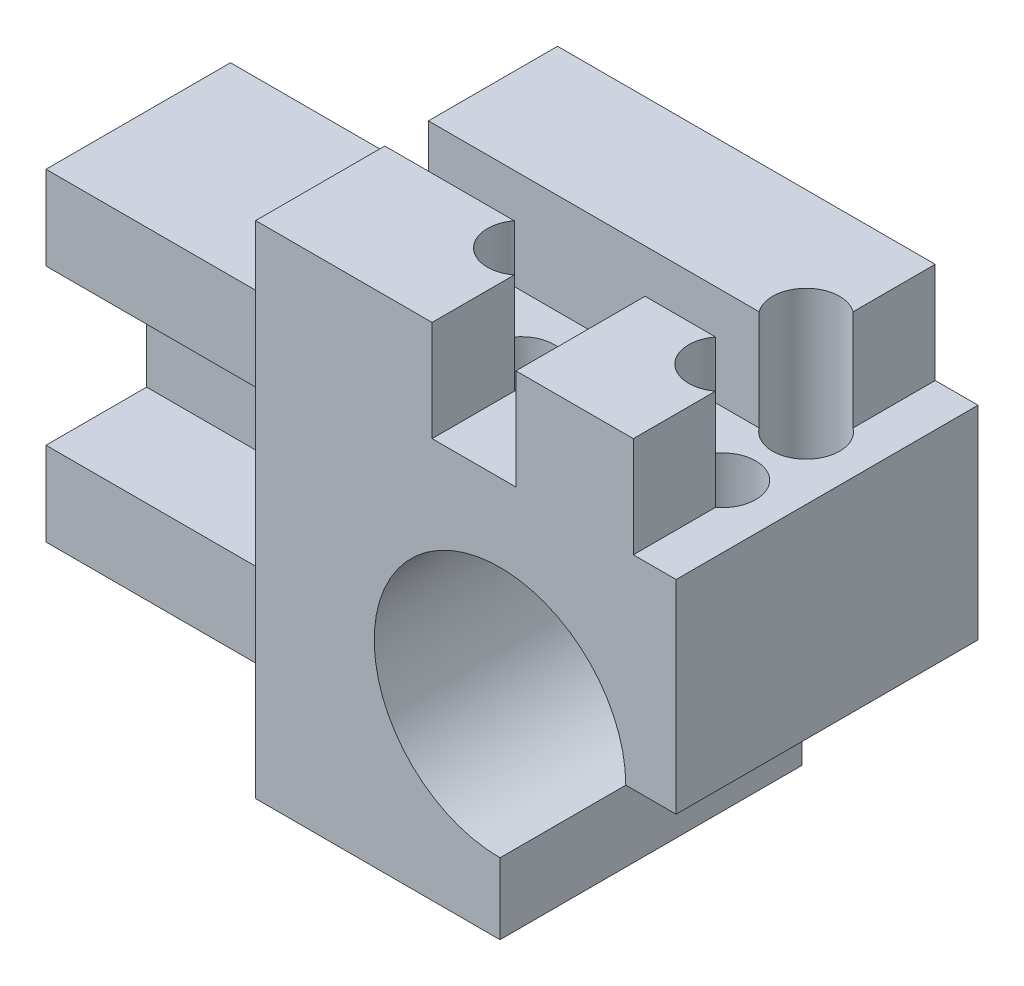
from build123d import *

# Parameters (mm, degrees)
SKETCH1_W               = 8.56892
SKETCH1_H               = 8.11892
BOSS_EXTRUDE1_DEPTH     = 9
SKETCH4_W               = 19.5
SKETCH4_H               = 19.25
BOSS_EXTRUDE2_DEPTH     = 5
SKETCH5_W               = 19.5
SKETCH5_H               = 5
BOSS_EXTRUDE3_DEPTH     = 6
CUT_EXTRUDE1_DEPTH      = 6
SKETCH7_R               = 2
CUT_EXTRUDE2_DEPTH      = 10
CUT_EXTRUDE3_DEPTH      = 6
SKETCH11_R              = 7.5
SKETCH11_W              = 10.5
SKETCH11_H              = 11.73108
CUT_EXTRUDE5_DEPTH      = 10
CUT_EXTRUDE5_DEPTH_BACK = 10


with BuildPart() as part:
    # Sketch1 → Boss-Extrude1 (new body, symmetric)
    with BuildSketch(Plane.XY):
        Polygon((-16.5, -19.85), (0, -19.85), (0, 0), (8.56892, 0), (8.56892, 10), (-16.5, 10), align=None)
        with Locations((4.28446, -4.05946)):
            Rectangle(SKETCH1_W, SKETCH1_H)
    extrude(amount=BOSS_EXTRUDE1_DEPTH, both=True)

    # Sketch4 → Boss-Extrude2 (add)
    with BuildSketch(Plane(origin=(0, 0, -9), x_dir=(-1, 0, 0), z_dir=(0, 0, -1))):
        with Locations((26.25, -10.225)):
            Rectangle(SKETCH4_W, SKETCH4_H)
    extrude(amount=-BOSS_EXTRUDE2_DEPTH)

    # Sketch5 → Boss-Extrude3 (add)
    with BuildSketch(Plane.XY.offset(-4)):
        with Locations((-26.25, -17.35)):
            Rectangle(SKETCH5_W, SKETCH5_H)
        with Locations((-26.25, -3.1)):
            Rectangle(SKETCH5_W, SKETCH5_H)
    extrude(amount=BOSS_EXTRUDE3_DEPTH)

    # Sketch6 → Cut-Extrude1 (cut)
    with BuildSketch(Plane.XY.offset(-4)):
        with BuildLine():
            Line((-28, -8.475), (-26, -8.475))
            ThreePointArc((-26, -8.475), (-24.25, -10.225), (-26, -11.975))
            Line((-26, -11.975), (-28, -11.975))
            ThreePointArc((-28, -11.975), (-29.75, -10.225), (-28, -8.475))
        make_face()
    extrude(amount=-CUT_EXTRUDE1_DEPTH, mode=Mode.SUBTRACT)

    # Sketch7 → Cut-Extrude2 (cut)
    with BuildSketch(Plane(origin=(0, 10, 0), x_dir=(1, 0, 0), z_dir=(0, 1, 0))):
        with Locations((4.81892, 2.5)):
            Circle(SKETCH7_R)
        with Locations((4.81892, -2.5)):
            Circle(SKETCH7_R)
        with Locations((-7.18108, -2.5)):
            Circle(SKETCH7_R)
    extrude(amount=-CUT_EXTRUDE2_DEPTH, mode=Mode.SUBTRACT)

    # Sketch8 → Cut-Extrude3 (cut)
    with BuildSketch(Plane(origin=(0, 10, 0), x_dir=(1, 0, 0), z_dir=(0, 1, 0))):
        Polygon((6.01892, 1.3), (6.01892, 9), (8.56892, 9), (8.56892, -9), (6.01892, -9), (6.01892, -1.3), (-0.98108, -1.3), (-0.98108, -9), (-5.98108, -9), (-5.98108, -1.3), (-16.5, -1.3), (-16.5, 1.3), align=None)
    extrude(amount=-CUT_EXTRUDE3_DEPTH, mode=Mode.SUBTRACT)

    # Sketch11 → Cut-Extrude5 (cut, two sides)
    with BuildSketch(Plane.XY) as cut_extrude5_sk:
        with Locations((-1.93108, -8.11892)):
            Circle(SKETCH11_R)
        with Locations((3.31892, -13.98446)):
            Rectangle(SKETCH11_W, SKETCH11_H)
    extrude(amount=CUT_EXTRUDE5_DEPTH, mode=Mode.SUBTRACT)
    extrude(cut_extrude5_sk.sketch, amount=-CUT_EXTRUDE5_DEPTH_BACK, mode=Mode.SUBTRACT)


solid = part.part
